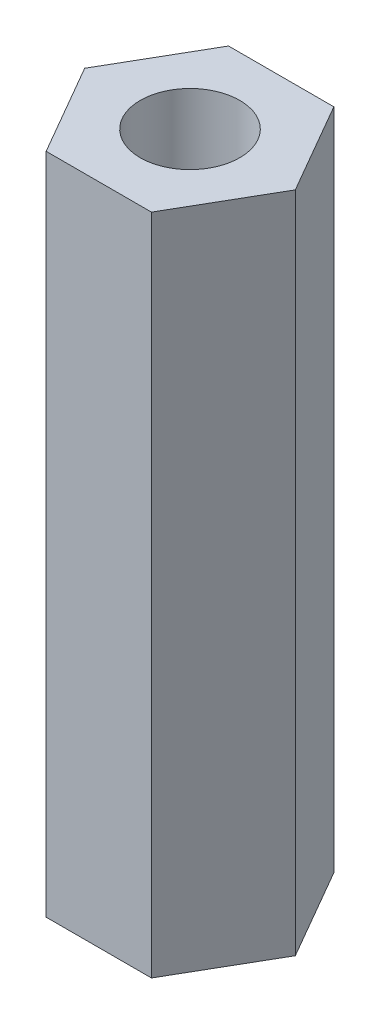
from build123d import *

# Parameters (mm, degrees)
SKETCH1_R           = 1.5
BOSS_EXTRUDE1_DEPTH = 20


with BuildPart() as part:
    # Sketch1 → Boss-Extrude1 (new body)
    with BuildSketch(Plane(origin=(0, 0, 0), x_dir=(1, 0, 0), z_dir=(0, 1, 0))):
        Polygon((3.175426481, 0), (1.58771324, 2.75), (-1.58771324, 2.75), (-3.175426481, 0), (-1.58771324, -2.75), (1.58771324, -2.75), align=None)
        Circle(SKETCH1_R, mode=Mode.SUBTRACT)
    extrude(amount=BOSS_EXTRUDE1_DEPTH)


solid = part.part
